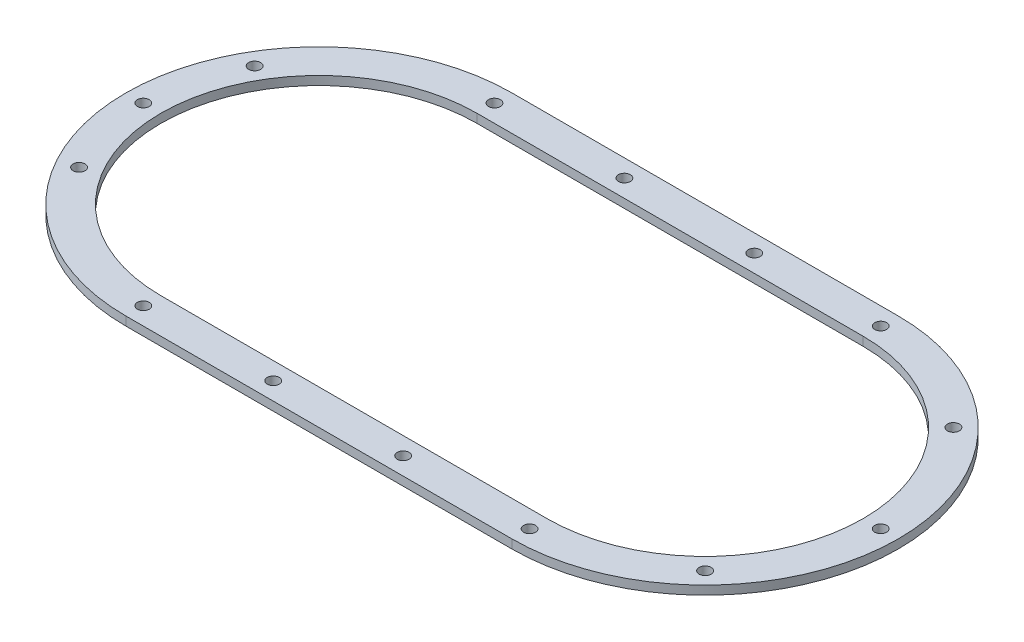
from build123d import *

# Parameters (mm, degrees)
BOSS_EXTRUDE1_DEPTH          = 5
TAP_DRILL_FOR_M8X1_25_TAP1_D = 6.8


with BuildPart() as part:
    # Sketch1 → Boss-Extrude1 (new body)
    with BuildSketch(Plane(origin=(0, 0, 0), x_dir=(1, 0, 0), z_dir=(0, 1, 0))):
        with BuildLine():
            Line((0, 110), (220, 110))
            ThreePointArc((220, 110), (330, 0), (220, -110))
            Line((220, -110), (0, -110))
            ThreePointArc((0, -110), (-110, 0), (0, 110))
        make_face()
        with BuildLine():
            Line((0, 90), (220, 90))
            ThreePointArc((220, 90), (310, 0), (220, -90))
            Line((220, -90), (0, -90))
            ThreePointArc((0, -90), (-90, 0), (0, 90))
        make_face(mode=Mode.SUBTRACT)
    extrude(amount=BOSS_EXTRUDE1_DEPTH)

    # Tap Drill for M8x1.25 Tap1 (through all)
    with Locations(Plane(origin=(0, 5, 0), x_dir=(1, 0, 0), z_dir=(0, 1, 0))):
        with Locations((-86.602540378, -50), (0, -100), (220, 100), (-100, 0), (-86.602540378, 50), (0, 100), (74, 100), (148, 100), (290.710678119, 70.710678119), (320, 0), (290.710678119, -70.710678119), (220, -100), (148, -100), (74, -100)):
            Hole(TAP_DRILL_FOR_M8X1_25_TAP1_D / 2)


solid = part.part
